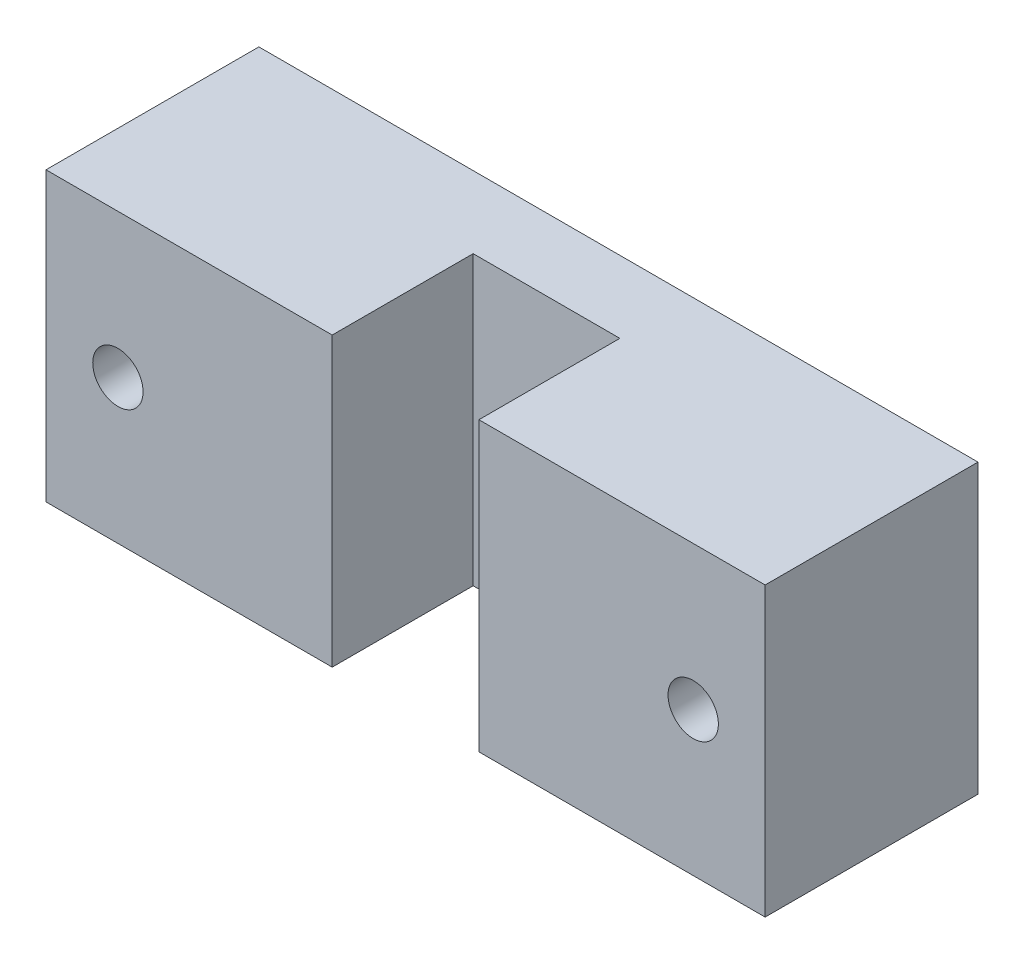
from build123d import *

# Parameters (mm, degrees)
SKETCH2_W           = 50
SKETCH2_H           = 20
SKETCH2_R           = 1.75
BOSS_EXTRUDE1_DEPTH = 5
BOSS_EXTRUDE2_DEPTH = 20
SKETCH6_R           = 1.75
CUT_EXTRUDE1_DEPTH  = 15.8


with BuildPart() as part:
    # Sketch2 → Boss-Extrude1 (new body)
    with BuildSketch(Plane.XY):
        Rectangle(SKETCH2_W, SKETCH2_H)
        with Locations((-20, 0)):
            Circle(SKETCH2_R, mode=Mode.SUBTRACT)
        with Locations((20, 0)):
            Circle(SKETCH2_R, mode=Mode.SUBTRACT)
    extrude(amount=BOSS_EXTRUDE1_DEPTH)

    # Sketch5 → Boss-Extrude2 (add)
    with BuildSketch(Plane.XZ.offset(10)):
        with BuildLine():
            Line((-25, 5), (-25, 14.8))
            Line((-25, 14.8), (-5.1, 14.8))
            Line((-5.1, 14.8), (-5.1, 5))
            Line((-5.1, 5), (5.1, 5))
            Line((5.1, 5), (5.1, 14.8))
            Line((5.1, 14.8), (25, 14.8))
            Line((25, 14.8), (25, 5))
            ThreePointArc((25, 5), (0, 0), (-25, 5))
        make_face()
    extrude(amount=-BOSS_EXTRUDE2_DEPTH)

    # Sketch6 → Cut-Extrude1 (cut, through all)
    with BuildSketch(Plane(origin=(0, 0, 0), x_dir=(-1, 0, 0), z_dir=(0, 0, -1))):
        with Locations((20, 0)):
            Circle(SKETCH6_R)
        with Locations((-20, 0)):
            Circle(SKETCH6_R)
    extrude(amount=-CUT_EXTRUDE1_DEPTH, mode=Mode.SUBTRACT)


solid = part.part
